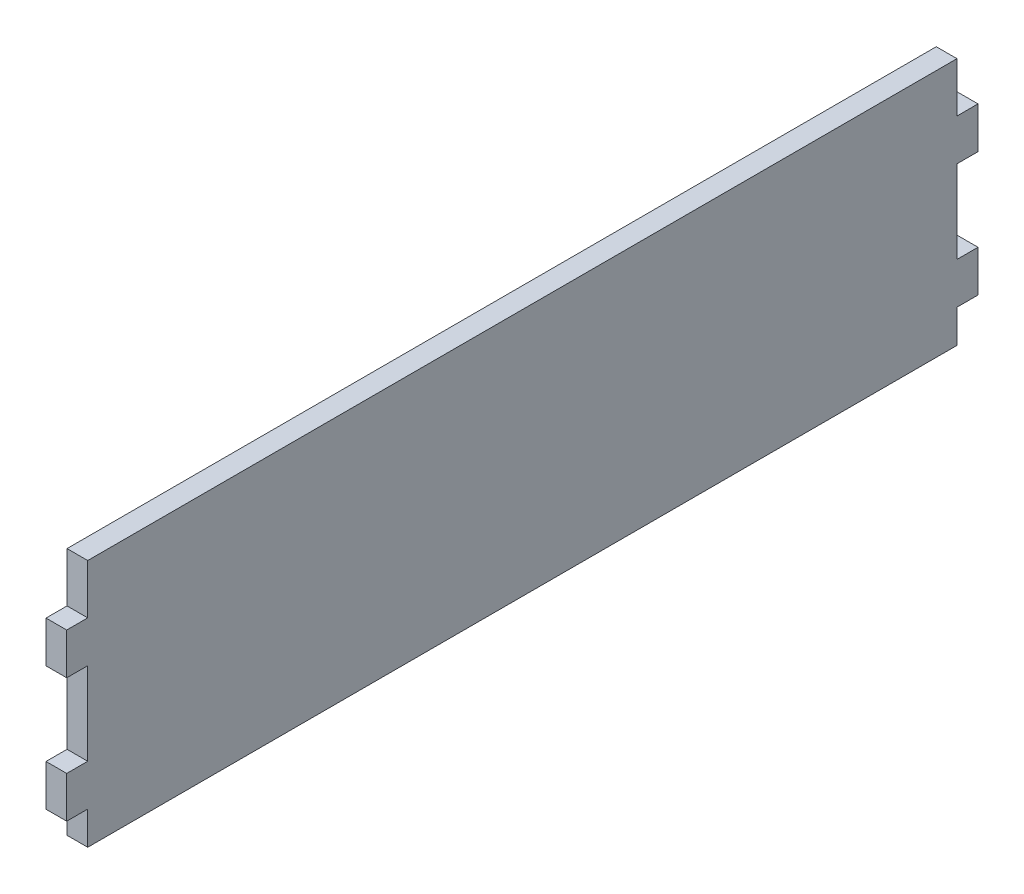
from build123d import *

# Parameters (mm, degrees)
SKETCH1_W           = 133.35
SKETCH1_H           = 38.1
BOSS_EXTRUDE1_DEPTH = 3.175
SKETCH2_W           = 3.2258
SKETCH2_H           = 6.35
BOSS_EXTRUDE2_DEPTH = 3.175


with BuildPart() as part:
    # Sketch1 → Boss-Extrude1 (new body)
    with BuildSketch(Plane(origin=(0, 0, 0), x_dir=(0, 0, -1), z_dir=(1, 0, 0))):
        Rectangle(SKETCH1_W, SKETCH1_H)
    extrude(amount=BOSS_EXTRUDE1_DEPTH)

    # Sketch2 → Boss-Extrude2 (add)
    with BuildSketch(Plane.ZY):
        with Locations((-68.2879, 8.255)):
            Rectangle(SKETCH2_W, SKETCH2_H)
        with Locations((-68.2879, -10.795)):
            Rectangle(SKETCH2_W, SKETCH2_H)
    boss_extrude2 = extrude(amount=-BOSS_EXTRUDE2_DEPTH)

    # Mirror1: Boss-Extrude2 across plane
    add(boss_extrude2.mirror(Plane.XY))


solid = part.part
